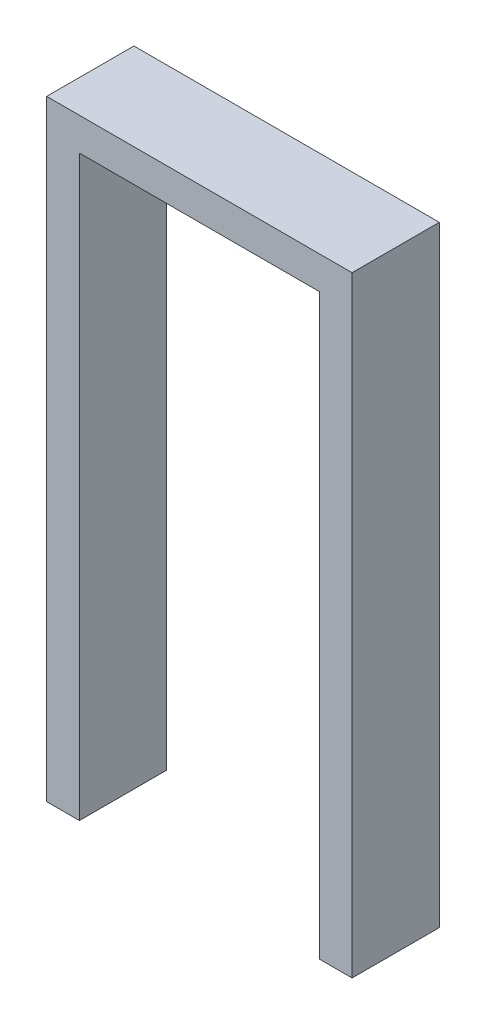
from build123d import *

# Parameters (mm, degrees)
BOSS_EXTRUDE1_DEPTH = 101.6


with BuildPart() as part:
    # Sketch1 → Boss-Extrude1 (new body)
    with BuildSketch(Plane.XY):
        Polygon((317.5, -673.1), (279.4, -673.1), (279.4, 0), (0, 0), (0, -673.1), (-38.1, -673.1), (-38.1, 38.1), (317.5, 38.1), align=None)
    extrude(amount=BOSS_EXTRUDE1_DEPTH)


solid = part.part
